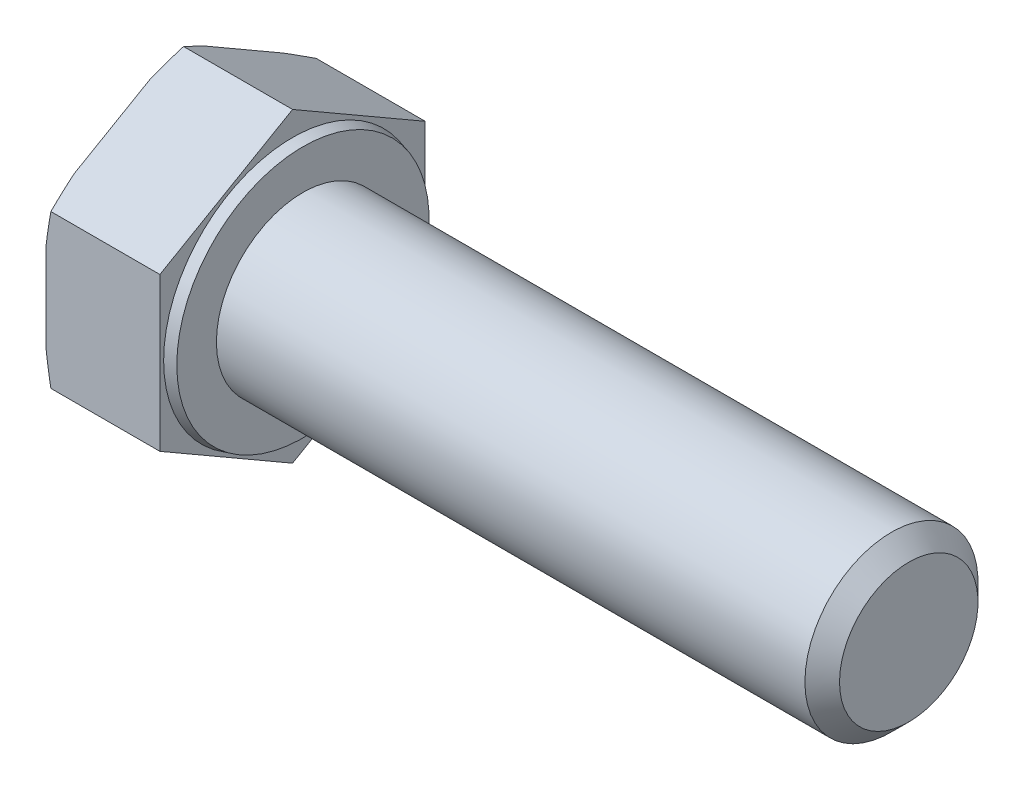
from build123d import *

# Parameters (mm, degrees)
SKETCH_2_OUTSIDE_W  = 29.51
SKETCH_2_OUTSIDE_H  = 29.51
CUT_EXTRUDE_1_DEPTH = 44.997697667
CHAMFER_1_SIZE      = 1


with BuildPart() as part:
    # Эскиз1 → Повернуть1 (revolve)
    with BuildSketch(Plane.XY, mode=Mode.PRIVATE) as revolve_1_sk:
        Polygon((-6.58, 0), (-6.58, 8.85), (0, 8.85), (0, 7.448974596), (0.6, 7.288205081), (0.6, 5), (35.6, 5), (35.6, 0), align=None)
    revolve(revolve_1_sk.sketch.rotate(Axis((-1000, 0, 0), (1, 0, 0)), 90), axis=Axis((-1000, 0, 0), (1, 0, 0)))

    # Эскиз2 outside → Вырез-Вытянуть1 (cut, through all)
    with BuildSketch(Plane.ZY.offset(6.58)):
        Rectangle(SKETCH_2_OUTSIDE_W, SKETCH_2_OUTSIDE_H)
        Polygon((0, -8.85), (7.664324823, -4.425), (7.664324823, 4.425), (0, 8.85), (-7.664324823, 4.425), (-7.664324823, -4.425), align=None, mode=Mode.SUBTRACT)
    extrude(amount=-CUT_EXTRUDE_1_DEPTH, mode=Mode.SUBTRACT)

    # Эскиз4 → Вырез-Повернуть1 (revolve, cut)
    with BuildSketch(Plane.XY):
        Polygon((-6.58, 8.075), (-6.297923068, 8.85), (-6.58, 8.85), align=None)
    revolve(axis=Axis((-1000, 0, 0), (1, 0, 0)), mode=Mode.SUBTRACT)

    # Фаска1
    chamfer_1_edges = [part.edges().sort_by_distance(p)[0] for p in [
        (35.6, 0, -5),
    ]]
    chamfer(chamfer_1_edges, length=CHAMFER_1_SIZE)


solid = part.part
